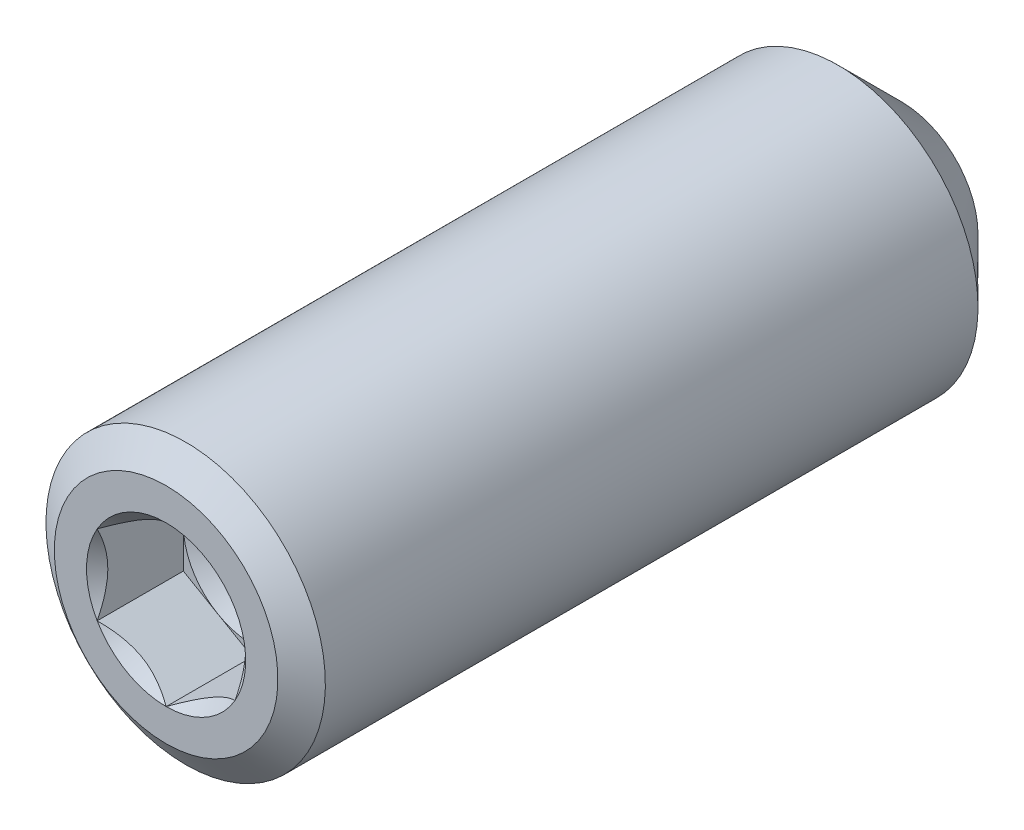
from build123d import *

# Parameters (mm, degrees)
CUT_EXTRUDE10_DEPTH = 1.48828125


with BuildPart() as part:
    # Sketch22 → Revolve1 (revolve)
    with BuildSketch(Plane(origin=(0, 0, 0), x_dir=(0, 0, -1), z_dir=(1, 0, 0))):
        Polygon((-5.952759232, 0), (-5.952759232, 1.9304), (-5.614839074, 2.413), (5.656480087, 2.413), (6.747240768, 1.322239319), (5.952759232, 0), align=None)
    revolve(axis=Axis((0, 0, -5.952759232), (0, 0, -1)))

    # Sketch23 → Cut-Extrude10 (cut)
    with BuildSketch(Plane.XY.offset(5.952759232)):
        Polygon((0, 1.374815329), (-1.190625, 0.687407664), (-1.190625, -0.687407664), (0, -1.374815329), (1.190625, -0.687407664), (1.190625, 0.687407664), align=None)
    extrude(amount=-CUT_EXTRUDE10_DEPTH, mode=Mode.SUBTRACT)

    # Cut-Extrude11 cone 1 section (through the dimple's axis) → Cut-Extrude11 (revolve, cut)
    with BuildSketch(Plane(origin=(0, 0, 5.952759232), x_dir=(0, -1, 0), z_dir=(1, 0, 0))):
        Polygon((0, 0), (1.374815329, 0), (0, 1.374815329), align=None)
    revolve(axis=Axis((0, 0, 5.952759232), (0, 0, -1)), mode=Mode.SUBTRACT)

    # Cut-Extrude12 cone 1 section (through the dimple's axis) → Cut-Extrude12 (revolve, cut)
    with BuildSketch(Plane(origin=(0, 0, 4.464477982), x_dir=(0, -1, 0), z_dir=(1, 0, 0))):
        Polygon((0, 0), (1.190625, 0), (0, 0.687407664), align=None)
    revolve(axis=Axis((0, 0, 4.464477982), (0, 0, -1)), mode=Mode.SUBTRACT)


solid = part.part
